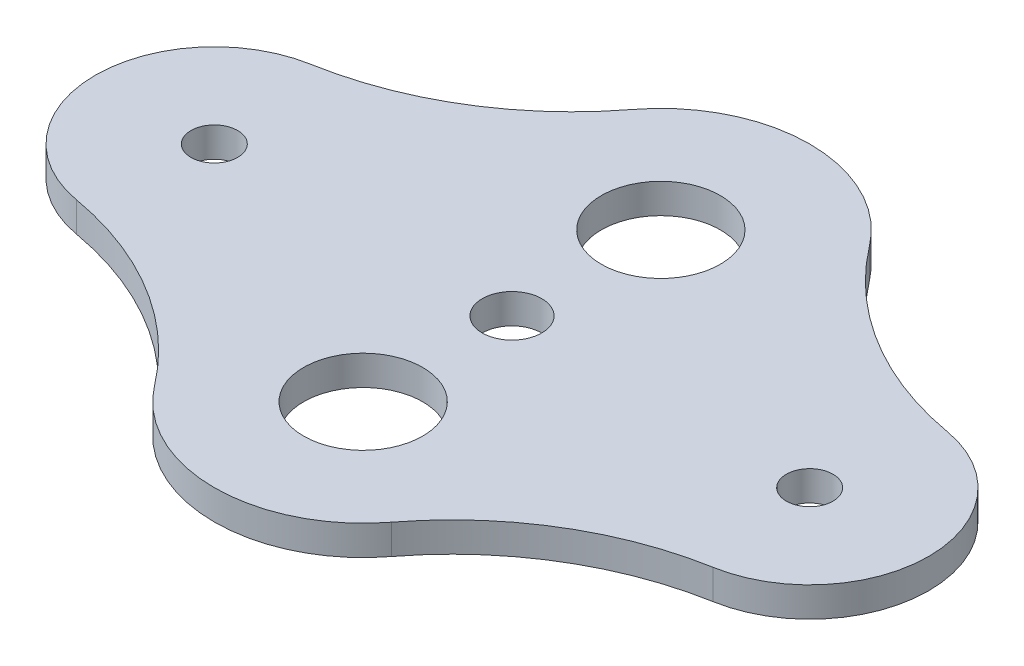
from build123d import *

# Parameters (mm, degrees)
BOSS_EXTRUDE1_DEPTH         = 3.175
F_1_4_0_25_DIAMETER_HOLE1_D = 6.35
SKETCH5_R                   = 6.35
CUT_EXTRUDE1_DEPTH          = 4.175
SKETCH6_R                   = 2.4892
CUT_EXTRUDE2_DEPTH          = 4.175


with BuildPart() as part:
    # Sketch1 → Boss-Extrude1 (new body)
    with BuildSketch(Plane(origin=(0, 0, 0), x_dir=(1, 0, 0), z_dir=(0, 1, 0))):
        with BuildLine():
            ThreePointArc((12.62743016, 25.495999561), (0, 31.75), (-12.62743016, 25.495999561))
            ThreePointArc((-12.62743016, 25.495999561), (-22.066120108, 16.991504417), (-33.953426839, 12.50739422))
            ThreePointArc((-33.953426839, 12.50739422), (-44.45, 0), (-33.953426839, -12.50739422))
            ThreePointArc((-33.953426839, -12.50739422), (-22.066120108, -16.991504417), (-12.62743016, -25.495999561))
            ThreePointArc((-12.62743016, -25.495999561), (0, -31.75), (12.62743016, -25.495999561))
            ThreePointArc((12.62743016, -25.495999561), (22.066120108, -16.991504417), (33.953426839, -12.50739422))
            ThreePointArc((33.953426839, -12.50739422), (44.45, 0), (33.953426839, 12.50739422))
            ThreePointArc((33.953426839, 12.50739422), (22.066120108, 16.991504417), (12.62743016, 25.495999561))
        make_face()
    extrude(amount=BOSS_EXTRUDE1_DEPTH)

    # 1/4 (0.25) Diameter Hole1 (through all)
    with Locations(Plane(origin=(0, 3.175, 0), x_dir=(1, 0, 0), z_dir=(0, 1, 0))):
        with Locations((0, 0)):
            Hole(F_1_4_0_25_DIAMETER_HOLE1_D / 2)

    # Sketch5 → Cut-Extrude1 (cut, through all)
    with BuildSketch(Plane(origin=(0, 3.175, 0), x_dir=(1, 0, 0), z_dir=(0, 1, 0))):
        with Locations((0, 15.875)):
            Circle(SKETCH5_R)
        with Locations((0, -15.875)):
            Circle(SKETCH5_R)
    extrude(amount=-CUT_EXTRUDE1_DEPTH, mode=Mode.SUBTRACT)

    # Sketch6 → Cut-Extrude2 (cut, through all)
    with BuildSketch(Plane(origin=(0, 3.175, 0), x_dir=(1, 0, 0), z_dir=(0, 1, 0))):
        with Locations((-31.75, 0)):
            Circle(SKETCH6_R)
        with Locations((31.75, 0)):
            Circle(SKETCH6_R)
    extrude(amount=-CUT_EXTRUDE2_DEPTH, mode=Mode.SUBTRACT)


solid = part.part
